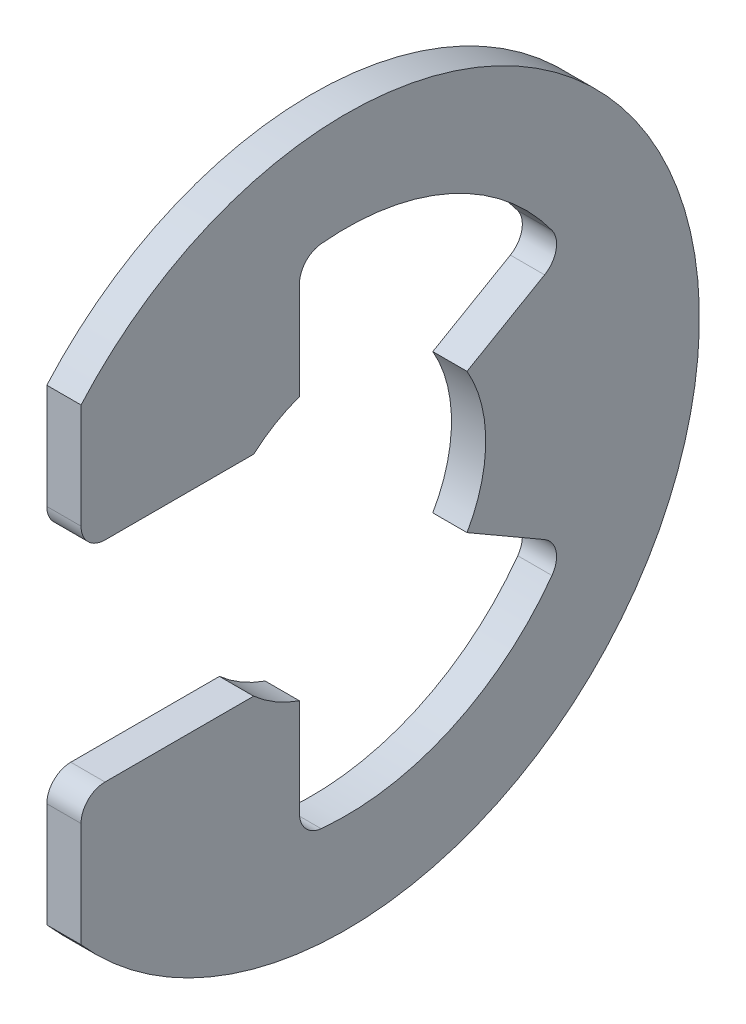
from build123d import *

# Parameters (mm, degrees)
EXTRUDE1_DEPTH = 0.3175
FILLET1_R      = 0.4445


with BuildPart() as part:
    # Sketch1 → Extrude1 (new body, symmetric)
    with BuildSketch(Plane(origin=(0, 0, 0), x_dir=(0, 0, -1), z_dir=(1, 0, 0))):
        with BuildLine():
            Line((-1.713653124, 1.9431), (-4.9149, 1.9431))
            Line((-4.9149, 1.9431), (-4.9149, 4.334534373))
            ThreePointArc((-4.9149, 4.334534373), (6.5532, 0), (-4.9149, -4.334534373))
            Line((-4.9149, -4.334534373), (-4.9149, -1.9431))
            Line((-4.9149, -1.9431), (-1.713653124, -1.9431))
            ThreePointArc((-1.713653124, -1.9431), (-1.312608429, -2.233674943), (-0.8636, -2.442629665))
            Line((-0.8636, -2.442629665), (-0.8636, -4.639797738))
            ThreePointArc((-0.8636, -4.639797738), (1.974221733, -4.286720956), (4.087192925, -2.359741935))
            Line((4.087192925, -2.359741935), (2.243698616, -1.2954))
            ThreePointArc((2.243698616, -1.2954), (2.5908, 0), (2.243698616, 1.2954))
            Line((2.243698616, 1.2954), (4.087192925, 2.359741935))
            ThreePointArc((4.087192925, 2.359741935), (1.974221733, 4.286720956), (-0.8636, 4.639797738))
            Line((-0.8636, 4.639797738), (-0.8636, 2.442629665))
            ThreePointArc((-0.8636, 2.442629665), (-1.312608429, 2.233674943), (-1.713653124, 1.9431))
        make_face()
    extrude(amount=EXTRUDE1_DEPTH, both=True)

    # Fillet1
    fillet1_edges = [part.edges().sort_by_distance(p)[0] for p in [
        (0, -1.9431, 4.9149),
        (0, -4.639797738, 0.8636),
        (0, -2.359741935, -4.087192925),
        (0, 2.359741935, -4.087192925),
        (0, 4.639797738, 0.8636),
        (0, 1.9431, 4.9149),
    ]]
    fillet(fillet1_edges, radius=FILLET1_R)


solid = part.part
